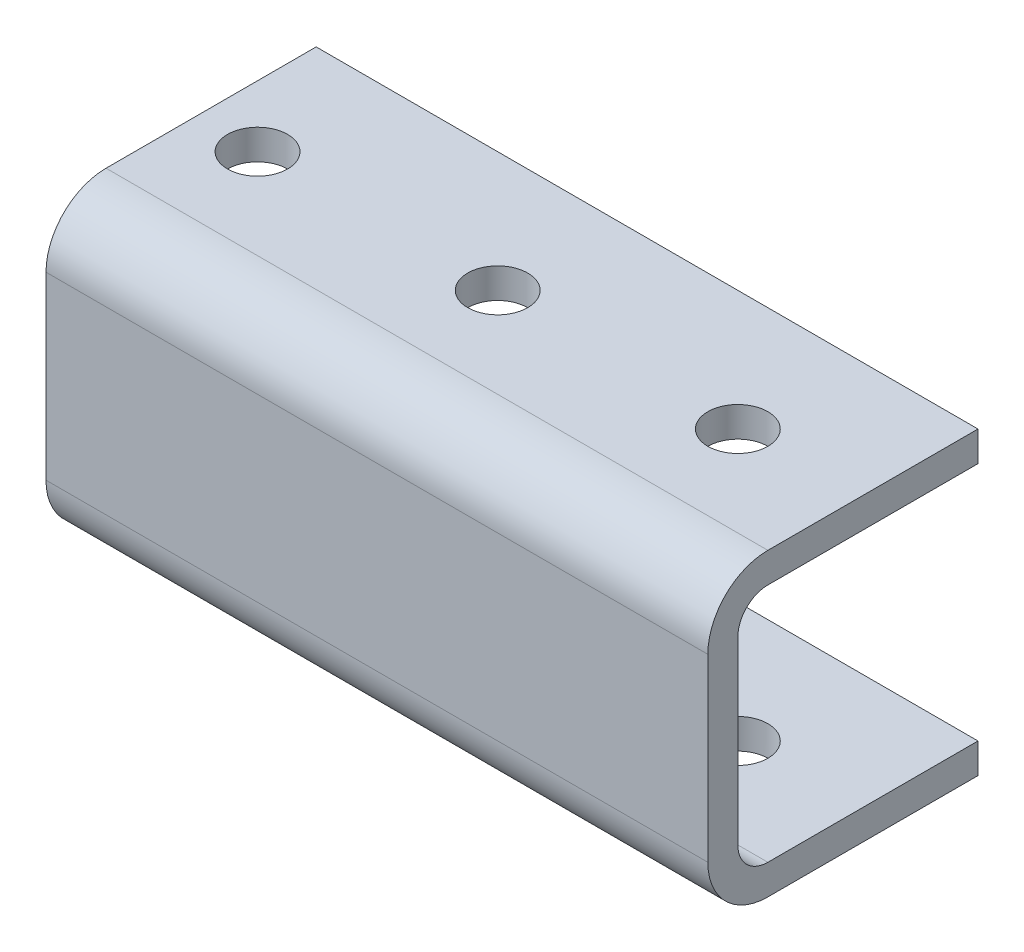
from build123d import *

# Parameters (mm, degrees)
SKETCH1_W          = 889
SKETCH1_H          = 31.75
EXTRUDE1_DEPTH     = 28.575
EXTRUDE2_REACH     = 891.702
SKETCH2_W          = 25.4
SKETCH2_H          = 25.4
HOLE1_D            = 6.35
HOLE1_DEPTH        = 3.175
LPATTERN1_COUNT    = 35
LPATTERN1_PITCH    = 25.4
HOLE2_D            = 9.652
LPATTERN2_COUNT    = 12
LPATTERN2_PITCH    = 25.4
HOLE3_D            = 9.652
HOLE4_D            = 9.652
LPATTERN3_COUNT    = 12
LPATTERN3_PITCH    = 25.4
HOLE5_D            = 3.175
HOLE6_D            = 6.35
LPATTERN4_COUNT    = 35
LPATTERN4_PITCH    = 25.4
FILLET1_R          = 3.175
FILLET2_R          = 3.175
FILLET3_R          = 6.35
FILLET4_R          = 6.35
SKETCH16_W         = 145.760071232
SKETCH16_H         = 71.504803879
CUT_EXTRUDE2_DEPTH = 75
SKETCH17_W         = 473.628565651
SKETCH17_H         = 66.908943447
CUT_EXTRUDE3_DEPTH = 186
SKETCH18_W         = 373.094897193
SKETCH18_H         = 93.915816603
CUT_EXTRUDE4_DEPTH = 186


with BuildPart() as part:
    # Sketch1 → Extrude1 (new body)
    with BuildSketch(Plane.XY.offset(3.175)):
        with Locations((428.480011997, 8.672957166)):
            Rectangle(SKETCH1_W, SKETCH1_H)
    extrude(amount=-EXTRUDE1_DEPTH)

    # Sketch2 → Extrude2 (cut, up to next)
    with BuildSketch(Plane.ZY.offset(16.019988003), mode=Mode.PRIVATE) as extrude2_sk1:
        with Locations((-12.7, 8.672957166)):
            Rectangle(SKETCH2_W, SKETCH2_H)
    extrude2_tool1 = extrude(extrude2_sk1.sketch, amount=-EXTRUDE2_REACH, mode=Mode.PRIVATE) & part.part
    add(extrude2_tool1.solids().sort_by_distance((-16.019988, 8.672957, -12.7))[0], mode=Mode.SUBTRACT)

    # Hole1
    with Locations(Plane(origin=(0, 24.547957166, 0), x_dir=(-1, 0, 0), z_dir=(0, 1, 0))):
        with Locations((3.319988003, -12.7)):
            hole1 = Hole(HOLE1_D / 2, depth=HOLE1_DEPTH)

    # LPattern1: Hole1 ×35
    with Locations(*[(i * LPATTERN1_PITCH, 0, 0) for i in range(1, LPATTERN1_COUNT)]):
        add(hole1, mode=Mode.SUBTRACT)

    # Hole2 (through all)
    with Locations(Plane.XY.offset(3.175)):
        with Locations((66.530011997, 10.577957166)):
            hole2 = Hole(HOLE2_D / 2)

    # LPattern2: Hole2 ×12, 8 skipped
    with Locations(*[(i * LPATTERN2_PITCH, 0, 0) for i in range(1, LPATTERN2_COUNT) if i not in (2, 3, 4, 5, 6, 7, 8, 9)]):
        add(hole2, mode=Mode.SUBTRACT)

    # Hole3 (through all)
    with Locations(Plane.XY.offset(3.175)):
        with Locations((428.480011997, 6.767957166)):
            Hole(HOLE3_D / 2)

    # Hole4 (through all)
    with Locations(Plane.XY.offset(3.175)):
        with Locations((511.030011997, 10.577957166)):
            hole4 = Hole(HOLE4_D / 2)

    # LPattern3: Hole4 ×12, 8 skipped
    with Locations(*[(i * LPATTERN3_PITCH, 0, 0) for i in range(1, LPATTERN3_COUNT) if i not in (2, 3, 4, 5, 6, 7, 8, 9)]):
        add(hole4, mode=Mode.SUBTRACT)

    # Hole5 (through all)
    with Locations(Plane.XY.offset(3.175)):
        with Locations((669.780011997, 8.672957166)):
            Hole(HOLE5_D / 2)

    # Hole6 (through all)
    with Locations(Plane(origin=(0, -4.027042834, 0), x_dir=(-1, 0, 0), z_dir=(0, 1, 0))):
        with Locations((3.319988003, -12.7)):
            hole6 = Hole(HOLE6_D / 2)

    # LPattern4: Hole6 ×35
    with Locations(*[(i * LPATTERN4_PITCH, 0, 0) for i in range(1, LPATTERN4_COUNT)]):
        add(hole6, mode=Mode.SUBTRACT)

    # Fillet1
    fillet1_edges = [part.edges().sort_by_distance(p)[0] for p in [
        (428.480011997, 21.372957166, 0),
    ]]
    fillet(fillet1_edges, radius=FILLET1_R)

    # Fillet2
    fillet2_edges = [part.edges().sort_by_distance(p)[0] for p in [
        (428.480011997, -4.027042834, 0),
    ]]
    fillet(fillet2_edges, radius=FILLET2_R)

    # Fillet3
    fillet3_edges = [part.edges().sort_by_distance(p)[0] for p in [
        (428.480011997, -7.202042834, 3.175),
    ]]
    fillet(fillet3_edges, radius=FILLET3_R)

    # Fillet4
    fillet4_edges = [part.edges().sort_by_distance(p)[0] for p in [
        (428.480011997, 24.547957166, 3.175),
    ]]
    fillet(fillet4_edges, radius=FILLET4_R)

    # Sketch16 → Cut-Extrude2 (cut)
    with BuildSketch(Plane(origin=(0, 24.547957166, 0), x_dir=(1, 0, 0), z_dir=(0, 1, 0))):
        with Locations((40.099976381, -10.352401939)):
            Rectangle(SKETCH16_W, SKETCH16_H)
    extrude(amount=-CUT_EXTRUDE2_DEPTH, mode=Mode.SUBTRACT)

    # Sketch17 → Cut-Extrude3 (cut)
    with BuildSketch(Plane(origin=(0, 24.547957166, 0), x_dir=(1, 0, 0), z_dir=(0, 1, 0))):
        with Locations((288.165729172, -8.054471723)):
            Rectangle(SKETCH17_W, SKETCH17_H)
    extrude(amount=-CUT_EXTRUDE3_DEPTH, mode=Mode.SUBTRACT)

    # Sketch18 → Cut-Extrude4 (cut)
    with BuildSketch(Plane(origin=(0, 24.547957166, 0), x_dir=(1, 0, 0), z_dir=(0, 1, 0))):
        with Locations((616.432563401, -21.557908301)):
            Rectangle(SKETCH18_W, SKETCH18_H)
    extrude(amount=-CUT_EXTRUDE4_DEPTH, mode=Mode.SUBTRACT)


solid = part.part
